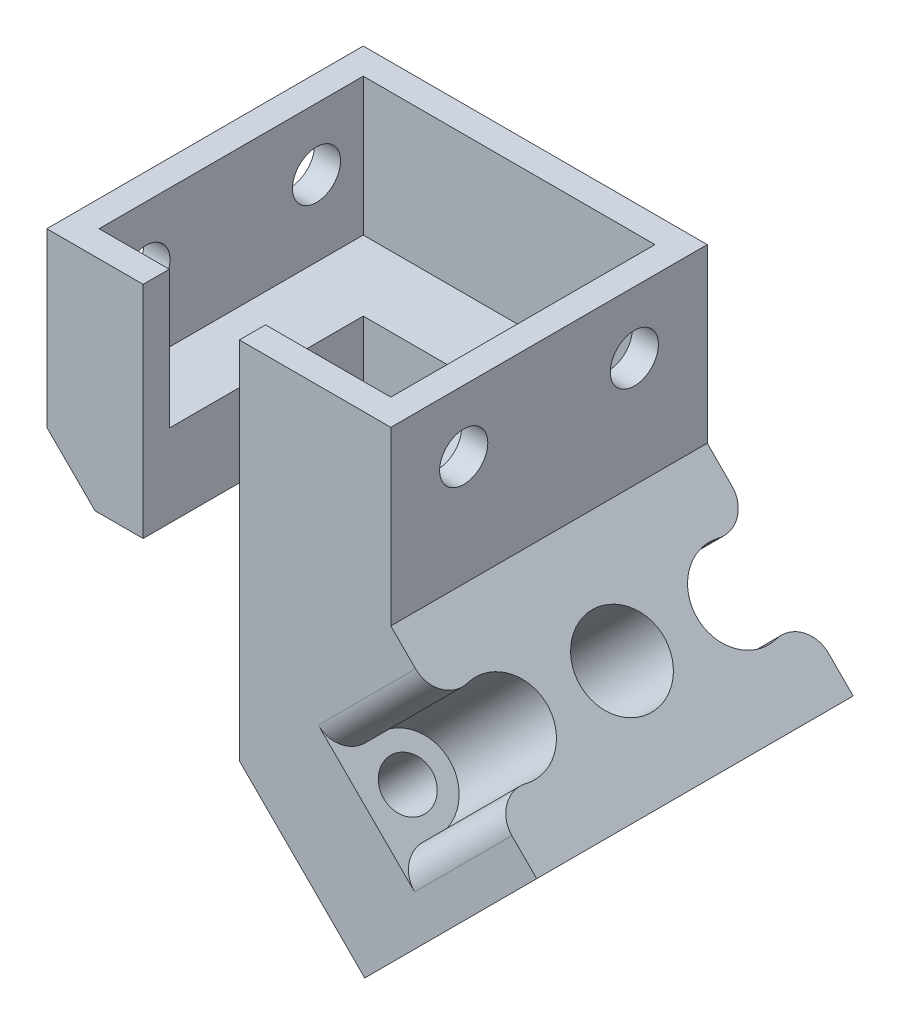
from build123d import *

# Parameters (mm, degrees)
SKETCH1_W           = 25
SKETCH1_H           = 23
BOSS_EXTRUDE1_DEPTH = 12.5
SKETCH4_W           = 21.2
SKETCH4_H           = 19.2
CUT_EXTRUDE2_DEPTH  = 10
BOSS_EXTRUDE2_DEPTH = 23
SKETCH2_W           = 7
SKETCH2_H           = 16
CUT_EXTRUDE1_DEPTH  = 16
BOSS_EXTRUDE3_DEPTH = 23
SKETCH7_R           = 1.75
CUT_EXTRUDE3_DEPTH  = 35.016504294
SKETCH8_R           = 3.05
CUT_EXTRUDE8_DEPTH  = 10
FILLET1_R           = 2
CUT_EXTRUDE9_DEPTH  = 2
SKETCH11_R          = 1.75
CUT_EXTRUDE10_DEPTH = 26
CUT_EXTRUDE11_DEPTH = 14


with BuildPart() as part:
    # Sketch1 → Boss-Extrude1 (new body)
    with BuildSketch(Plane(origin=(0, 0, 0), x_dir=(1, 0, 0), z_dir=(0, 1, 0))):
        with Locations((12.5, 11.5)):
            Rectangle(SKETCH1_W, SKETCH1_H)
    extrude(amount=BOSS_EXTRUDE1_DEPTH)

    # Sketch4 → Cut-Extrude2 (cut)
    with BuildSketch(Plane(origin=(0, 12.5, 0), x_dir=(1, 0, 0), z_dir=(0, 1, 0))):
        with Locations((12.5, 11.5)):
            Rectangle(SKETCH4_W, SKETCH4_H)
    extrude(amount=-CUT_EXTRUDE2_DEPTH, mode=Mode.SUBTRACT)

    # Sketch5 → Boss-Extrude2 (add)
    with BuildSketch(Plane.XY):
        Polygon((25, 0), (12.5, -12.5), (0, 0), align=None)
    extrude(amount=-BOSS_EXTRUDE2_DEPTH)

    # Sketch2 → Cut-Extrude1 (cut)
    with BuildSketch(Plane(origin=(0, 12.5, 0), x_dir=(1, 0, 0), z_dir=(0, 1, 0))):
        with Locations((10.5, 8)):
            Rectangle(SKETCH2_W, SKETCH2_H)
    extrude(amount=-CUT_EXTRUDE1_DEPTH, mode=Mode.SUBTRACT)

    # Sketch6 → Boss-Extrude3 (add)
    with BuildSketch(Plane.XY):
        Polygon((35.606601718, -10.606601718), (25, 0), (12.5, -12.5), (23.106601718, -23.106601718), align=None)
    extrude(amount=-BOSS_EXTRUDE3_DEPTH)

    # Sketch7 → Cut-Extrude3 (cut, through all)
    with BuildSketch(Plane(origin=(12.5, 12.5, 0), x_dir=(0, 0, -1), z_dir=(0.707106781, 0.707106781, 0))):
        with Locations((20, -25.17766953)):
            Circle(SKETCH7_R)
        with Locations((3, -25.17766953)):
            Circle(SKETCH7_R)
        with Locations((11.5, -25.17766953)):
            Circle(SKETCH7_R)
    extrude(amount=-CUT_EXTRUDE3_DEPTH, mode=Mode.SUBTRACT)

    # Sketch8 → Cut-Extrude8 (cut)
    with BuildSketch(Plane(origin=(12.5, 12.5, 0), x_dir=(0, 0, -1), z_dir=(0.707106781, 0.707106781, 0))):
        with Locations((20, -25.17766953)):
            Circle(SKETCH8_R)
        with Locations((11.5, -25.17766953)):
            Circle(SKETCH8_R)
        with Locations((3, -25.17766953)):
            Circle(SKETCH8_R)
    extrude(amount=-CUT_EXTRUDE8_DEPTH, mode=Mode.SUBTRACT)

    # Fillet1
    fillet1_edges = [part.edges().sort_by_distance(p)[0] for p in [
        (26.378858223, -8.449926035, 0),
        (27.156675683, -9.227743494, 0),
        (27.156675683, -9.227743494, -23),
        (26.378858223, -8.449926035, -23),
    ]]
    fillet(fillet1_edges, radius=FILLET1_R)

    # Sketch9 → Cut-Extrude9 (cut)
    with BuildSketch(Plane.XY):
        Polygon((7, -7), (14, -14), (14, -3.5), (7, -3.5), (3.5, -3.5), align=None)
    extrude(amount=-CUT_EXTRUDE9_DEPTH, mode=Mode.SUBTRACT)

    # Sketch11 → Cut-Extrude10 (cut, through all)
    with BuildSketch(Plane(origin=(25, 0, 0), x_dir=(0, 0, -1), z_dir=(1, 0, 0))):
        with Locations((5.3, 8)):
            Circle(SKETCH11_R)
        with Locations((17.7, 8)):
            Circle(SKETCH11_R)
    extrude(amount=-CUT_EXTRUDE10_DEPTH, mode=Mode.SUBTRACT)

    # Sketch12 → Cut-Extrude11 (cut)
    with BuildSketch(Plane.XY.offset(-2)):
        Polygon((3.5, -3.5), (14, -3.5), (14, -14), align=None)
    extrude(amount=-CUT_EXTRUDE11_DEPTH, mode=Mode.SUBTRACT)


solid = part.part
